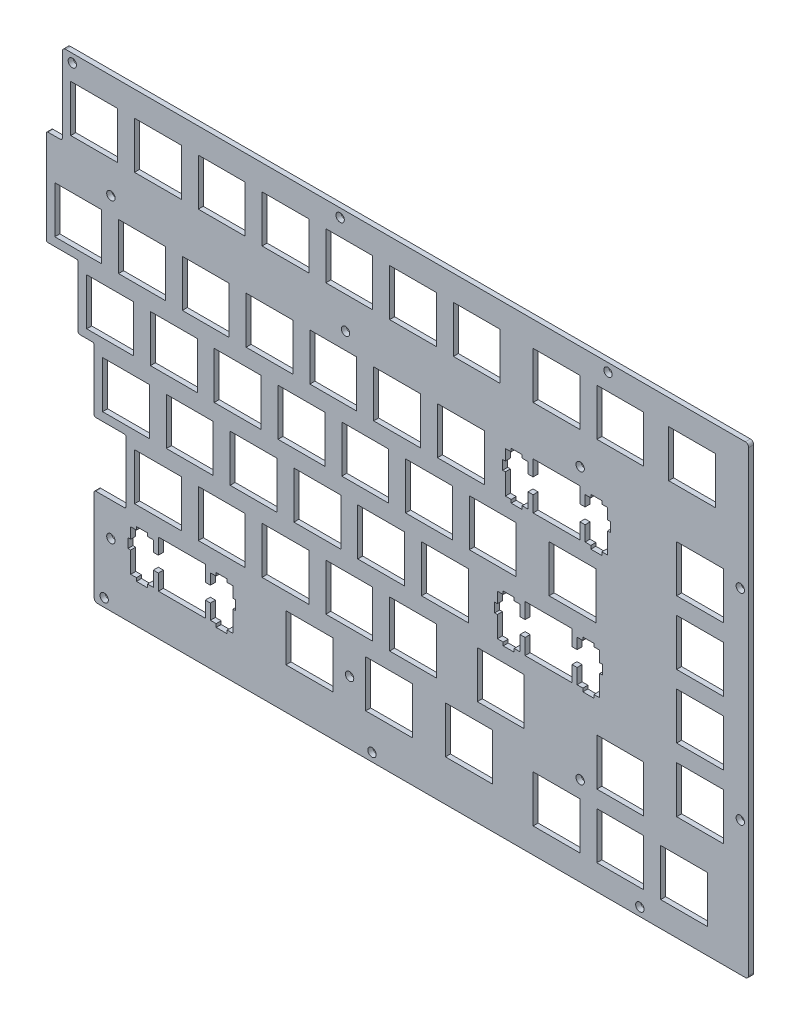
from build123d import *

# Parameters (mm, degrees)
MODEL_W                = 13.999
MODEL_H                = 13.99947
MODEL_W_2              = 13.9993
MODEL_H_2              = 13.99948
MODEL_W_3              = 14.0009
MODEL_H_3              = 13.9994
MODEL_W_4              = 14
MODEL_W_5              = 13.9994
MODEL_H_4              = 13.9992
MODEL_W_6              = 13.9998
MODEL_W_7              = 13.99955
MODEL_W_8              = 14.0007
MODEL_W_9              = 14.001
MODEL_W_10             = 13.99954
MODEL_H_5              = 13.999
EXTRUDE_1_DEPTH        = 1.5
EXTRUDE_2_DEPTH        = 1.5
SKETCH_2_R             = 1.25
CUT_EXTRUDE_1_DEPTH    = 3
FILLET_1_R             = 1
PATTERN_LINEAR_1_COUNT = 3
PATTERN_LINEAR_1_PITCH = 80
SKETCH_3_R             = 1.25
CUT_EXTRUDE_2_DEPTH    = 3
PATTERN_LINEAR_2_COUNT = 3
PATTERN_LINEAR_2_PITCH = 60
FILLET_2_R             = 0.5
SKETCH_4_R             = 1.25
CUT_EXTRUDE_3_DEPTH    = 10


with BuildPart() as part:
    # Model → 凸台-拉伸1 (new body)
    with BuildSketch(Plane.XY):
        Polygon((4.85693, 129.021), (204.883, 129.021), (204.883, 0.434082), (14.38193, 0.434082), (14.38193, 24.241), (23.90693, 24.241), (23.90693, 43.291), (14.38193, 43.291), (14.38193, 62.341), (9.61893, 62.341), (9.61893, 81.391), (0.09393, 81.391), (0.09393, 109.971), (4.85693, 109.971), align=None)
        with Locations((152.4945, 9.959765)):
            Rectangle(MODEL_W, MODEL_H, mode=Mode.SUBTRACT)
        with Locations((171.5445, 9.959765)):
            Rectangle(MODEL_W, MODEL_H, mode=Mode.SUBTRACT)
        with Locations((190.5945, 9.959765)):
            Rectangle(MODEL_W, MODEL_H, mode=Mode.SUBTRACT)
        Polygon((33.5759, 21.722), (33.5759, 17.0215), (32.0504, 17.0215), (32.0504, 20.2517), (30.3251, 20.2517), (30.3251, 21.1722), (27.0261, 21.1722), (27.0261, 20.2517), (25.3008, 20.2517), (25.3008, 17.0215), (24.4753, 17.0215), (24.4753, 14.2227), (25.3008, 14.2227), (25.3008, 7.95267), (27.0261, 7.95267), (27.0261, 6.97286), (30.3251, 6.97286), (30.3251, 7.95267), (32.0504, 7.95267), (32.0504, 12.4216), (33.5759, 12.4216), (33.5759, 7.72252), (47.5753, 7.72252), (47.5753, 12.4216), (49.101, 12.4216), (49.101, 7.95267), (50.8247, 7.95267), (50.8247, 6.97286), (54.1253, 6.97286), (54.1253, 7.95267), (55.8504, 7.95267), (55.8504, 14.2227), (56.6759, 14.2227), (56.6759, 17.0215), (55.8504, 17.0215), (55.8504, 20.2517), (54.1253, 20.2517), (54.1253, 21.1722), (50.8247, 21.1722), (50.8247, 20.2517), (49.101, 20.2517), (49.101, 17.0215), (47.5753, 17.0215), (47.5753, 21.722), align=None, mode=Mode.SUBTRACT)
        with Locations((78.67565, 14.72226)):
            Rectangle(MODEL_W_2, MODEL_H_2, mode=Mode.SUBTRACT)
        with Locations((102.48755, 14.72226)):
            Rectangle(MODEL_W_3, MODEL_H_2, mode=Mode.SUBTRACT)
        with Locations((126.3005, 14.72226)):
            Rectangle(MODEL_W, MODEL_H_2, mode=Mode.SUBTRACT)
        with Locations((171.5445, 29.0097)):
            Rectangle(MODEL_W, MODEL_H_3, mode=Mode.SUBTRACT)
        with Locations((33.43185, 33.7722)):
            Rectangle(MODEL_W_2, MODEL_H_3, mode=Mode.SUBTRACT)
        with Locations((52.48185, 33.7722)):
            Rectangle(MODEL_W_2, MODEL_H_3, mode=Mode.SUBTRACT)
        with Locations((71.53185, 33.7722)):
            Rectangle(MODEL_W_2, MODEL_H_3, mode=Mode.SUBTRACT)
        with Locations((90.58185, 33.7722)):
            Rectangle(MODEL_W_2, MODEL_H_3, mode=Mode.SUBTRACT)
        with Locations((109.632, 33.7722)):
            Rectangle(MODEL_W_4, MODEL_H_3, mode=Mode.SUBTRACT)
        with Locations((135.8255, 33.7722)):
            Rectangle(MODEL_W, MODEL_H_3, mode=Mode.SUBTRACT)
        with Locations((195.357, 33.7722)):
            Rectangle(MODEL_W_4, MODEL_H_3, mode=Mode.SUBTRACT)
        Polygon((143.112, 59.8219), (143.112, 55.1215), (141.588, 55.1215), (141.588, 58.3516), (139.863, 58.3516), (139.863, 59.2723), (136.562, 59.2723), (136.562, 58.3516), (134.837, 58.3516), (134.837, 55.1215), (134.013, 55.1215), (134.013, 52.3226), (134.837, 52.3226), (134.837, 46.0527), (136.562, 46.0527), (136.562, 45.0716), (139.863, 45.0716), (139.863, 46.0527), (141.588, 46.0527), (141.588, 50.5217), (143.112, 50.5217), (143.112, 45.8227), (157.113, 45.8227), (157.113, 50.5217), (158.637, 50.5217), (158.637, 46.0527), (160.362, 46.0527), (160.362, 45.0716), (163.663, 45.0716), (163.663, 46.0527), (165.388, 46.0527), (165.388, 52.3226), (166.212, 52.3226), (166.212, 55.1215), (165.388, 55.1215), (165.388, 58.3516), (163.663, 58.3516), (163.663, 59.2723), (160.362, 59.2723), (160.362, 58.3516), (158.637, 58.3516), (158.637, 55.1215), (157.113, 55.1215), (157.113, 59.8219), align=None, mode=Mode.SUBTRACT)
        with Locations((23.9069, 52.8223)):
            Rectangle(MODEL_W_5, MODEL_H_4, mode=Mode.SUBTRACT)
        with Locations((42.95685, 52.8223)):
            Rectangle(MODEL_W_2, MODEL_H_4, mode=Mode.SUBTRACT)
        with Locations((62.00685, 52.8223)):
            Rectangle(MODEL_W_2, MODEL_H_4, mode=Mode.SUBTRACT)
        with Locations((81.05685, 52.8223)):
            Rectangle(MODEL_W_2, MODEL_H_4, mode=Mode.SUBTRACT)
        with Locations((100.1071, 52.8223)):
            Rectangle(MODEL_W_6, MODEL_H_4, mode=Mode.SUBTRACT)
        with Locations((119.157, 52.8223)):
            Rectangle(MODEL_W_4, MODEL_H_4, mode=Mode.SUBTRACT)
        with Locations((195.357, 52.8223)):
            Rectangle(MODEL_W_4, MODEL_H_4, mode=Mode.SUBTRACT)
        with Locations((19.1444, 71.8723)):
            Rectangle(MODEL_W_5, MODEL_H_4, mode=Mode.SUBTRACT)
        with Locations((38.19435, 71.8723)):
            Rectangle(MODEL_W_2, MODEL_H_4, mode=Mode.SUBTRACT)
        with Locations((57.24435, 71.8723)):
            Rectangle(MODEL_W_2, MODEL_H_4, mode=Mode.SUBTRACT)
        with Locations((76.29435, 71.8723)):
            Rectangle(MODEL_W_2, MODEL_H_4, mode=Mode.SUBTRACT)
        with Locations((95.34435, 71.8723)):
            Rectangle(MODEL_W_2, MODEL_H_4, mode=Mode.SUBTRACT)
        with Locations((114.3945, 71.8723)):
            Rectangle(MODEL_W, MODEL_H_4, mode=Mode.SUBTRACT)
        with Locations((133.4445, 71.8723)):
            Rectangle(MODEL_W, MODEL_H_4, mode=Mode.SUBTRACT)
        with Locations((157.257, 71.8723)):
            Rectangle(MODEL_W_4, MODEL_H_4, mode=Mode.SUBTRACT)
        with Locations((195.357, 71.8723)):
            Rectangle(MODEL_W_4, MODEL_H_4, mode=Mode.SUBTRACT)
        Polygon((145.493, 97.9219), (145.493, 93.2215), (143.969, 93.2215), (143.969, 96.4516), (142.244, 96.4516), (142.244, 97.3723), (138.943, 97.3723), (138.943, 96.4516), (137.218, 96.4516), (137.218, 93.2215), (136.394, 93.2215), (136.394, 90.4226), (137.218, 90.4226), (137.218, 84.1527), (138.943, 84.1527), (138.943, 83.1716), (142.244, 83.1716), (142.244, 84.1527), (143.969, 84.1527), (143.969, 88.6217), (145.493, 88.6217), (145.493, 83.9227), (159.494, 83.9227), (159.494, 88.6217), (161.018, 88.6217), (161.018, 84.1527), (162.743, 84.1527), (162.743, 83.1716), (166.044, 83.1716), (166.044, 84.1527), (167.768, 84.1527), (167.768, 90.4226), (168.593, 90.4226), (168.593, 93.2215), (167.768, 93.2215), (167.768, 96.4516), (166.044, 96.4516), (166.044, 97.3723), (162.743, 97.3723), (162.743, 96.4516), (161.018, 96.4516), (161.018, 93.2215), (159.494, 93.2215), (159.494, 97.9219), align=None, mode=Mode.SUBTRACT)
        with Locations((9.619425, 90.9223)):
            Rectangle(MODEL_W_7, MODEL_H_4, mode=Mode.SUBTRACT)
        with Locations((28.66935, 90.9223)):
            Rectangle(MODEL_W_2, MODEL_H_4, mode=Mode.SUBTRACT)
        with Locations((47.71935, 90.9223)):
            Rectangle(MODEL_W_2, MODEL_H_4, mode=Mode.SUBTRACT)
        with Locations((66.76935, 90.9223)):
            Rectangle(MODEL_W_2, MODEL_H_4, mode=Mode.SUBTRACT)
        with Locations((85.81935, 90.9223)):
            Rectangle(MODEL_W_2, MODEL_H_4, mode=Mode.SUBTRACT)
        with Locations((104.86865, 90.9223)):
            Rectangle(MODEL_W_8, MODEL_H_4, mode=Mode.SUBTRACT)
        with Locations((123.9185, 90.9223)):
            Rectangle(MODEL_W_9, MODEL_H_4, mode=Mode.SUBTRACT)
        with Locations((195.357, 90.9223)):
            Rectangle(MODEL_W_4, MODEL_H_4, mode=Mode.SUBTRACT)
        with Locations((14.38193, 119.4975)):
            Rectangle(MODEL_W_10, MODEL_H_5, mode=Mode.SUBTRACT)
        with Locations((33.43185, 119.4975)):
            Rectangle(MODEL_W_2, MODEL_H_5, mode=Mode.SUBTRACT)
        with Locations((52.48185, 119.4975)):
            Rectangle(MODEL_W_2, MODEL_H_5, mode=Mode.SUBTRACT)
        with Locations((71.53185, 119.4975)):
            Rectangle(MODEL_W_2, MODEL_H_5, mode=Mode.SUBTRACT)
        with Locations((90.58185, 119.4975)):
            Rectangle(MODEL_W_2, MODEL_H_5, mode=Mode.SUBTRACT)
        with Locations((109.632, 119.4975)):
            Rectangle(MODEL_W_4, MODEL_H_5, mode=Mode.SUBTRACT)
        with Locations((128.682, 119.4975)):
            Rectangle(MODEL_W_4, MODEL_H_5, mode=Mode.SUBTRACT)
        with Locations((152.4945, 119.4975)):
            Rectangle(MODEL_W, MODEL_H_5, mode=Mode.SUBTRACT)
        with Locations((171.5445, 119.4975)):
            Rectangle(MODEL_W, MODEL_H_5, mode=Mode.SUBTRACT)
        with Locations((192.9755, 119.4975)):
            Rectangle(MODEL_W, MODEL_H_5, mode=Mode.SUBTRACT)
    extrude(amount=EXTRUDE_1_DEPTH)

    # 草图1 → 凸台-拉伸2 (add)
    with BuildSketch(Plane.XY.offset(1.5)):
        Polygon((14.38193, -4.565918), (209.883, -4.565918), (209.883, 134.021), (4.85693, 134.021), (4.85693, 129.021), (204.883, 129.021), (204.883, 0.434082), (14.38193, 0.434082), align=None)
    extrude(amount=-EXTRUDE_2_DEPTH)

    # 草图2 → 切除-拉伸1 (cut)
    with BuildSketch(Plane.XY.offset(1.5)):
        with Locations((7.85693, 131.521)):
            Circle(SKETCH_2_R)
        with Locations((17.38193, -2.065918)):
            Circle(SKETCH_2_R)
    cut_extrude_1 = extrude(amount=-CUT_EXTRUDE_1_DEPTH, mode=Mode.SUBTRACT)

    # 圆角1
    fillet_1_edges = [part.edges().sort_by_distance(p)[0] for p in [
        (14.38193, -4.565918, 0.75),
        (4.85693, 134.021, 0.75),
        (209.883, 134.021, 0.75),
        (209.883, -4.565918, 0.75),
    ]]
    fillet(fillet_1_edges, radius=FILLET_1_R)

    # 阵列(线性)1: 切除-拉伸1 ×3
    with Locations(*[(i * PATTERN_LINEAR_1_PITCH, 0, 0) for i in range(1, PATTERN_LINEAR_1_COUNT)]):
        add(cut_extrude_1, mode=Mode.SUBTRACT)

    # 草图3 → 切除-拉伸2 (cut)
    with BuildSketch(Plane.XY.offset(1.5)):
        with Locations((207.383, 35.434082)):
            Circle(SKETCH_3_R)
    cut_extrude_2 = extrude(amount=-CUT_EXTRUDE_2_DEPTH, mode=Mode.SUBTRACT)

    # 阵列(线性)2: 切除-拉伸2 ×3
    with Locations(*[(0, i * PATTERN_LINEAR_2_PITCH, 0) for i in range(1, PATTERN_LINEAR_2_COUNT)]):
        add(cut_extrude_2, mode=Mode.SUBTRACT)

    # 圆角2
    fillet_2_edges = [part.edges().sort_by_distance(p)[0] for p in [
        (14.38193, 24.241, 0.75),
        (23.90693, 24.241, 0.75),
        (23.90693, 43.291, 0.75),
        (14.38193, 43.291, 0.75),
        (14.38193, 62.341, 0.75),
        (9.61893, 62.341, 0.75),
        (9.61893, 81.391, 0.75),
        (0.09393, 81.391, 0.75),
        (0.09393, 109.971, 0.75),
        (4.85693, 109.971, 0.75),
    ]]
    fillet(fillet_2_edges, radius=FILLET_2_R)

    # 草图4 → 切除-拉伸3 (cut)
    with BuildSketch(Plane.XY.offset(1.5)):
        with Locations((19.38193, 102.9219)):
            Circle(SKETCH_4_R)
        with Locations((19.38193, 14.241)):
            Circle(SKETCH_4_R)
        with Locations((159.545, 21.9595)):
            Circle(SKETCH_4_R)
        with Locations((159.545, 102.9219)):
            Circle(SKETCH_4_R)
        with Locations((89.463465, 102.9219)):
            Circle(SKETCH_4_R)
        with Locations((90.6753, 14.241)):
            Circle(SKETCH_4_R)
    extrude(amount=-CUT_EXTRUDE_3_DEPTH, mode=Mode.SUBTRACT)


solid = part.part
